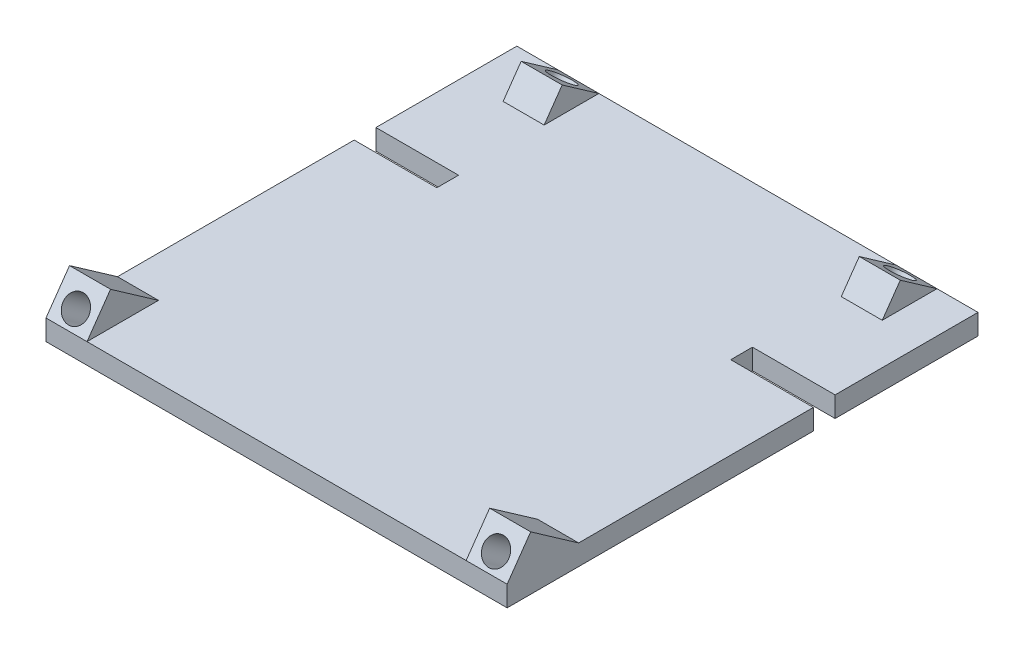
from build123d import *

# Parameters (mm, degrees)
BOSS_EXTRUDE1_DEPTH = 2.5
BOSS_EXTRUDE2_DEPTH = 10
SKETCH3_R           = 3.1
CUT_EXTRUDE1_DEPTH  = 97.926231277
BOSS_EXTRUDE3_DEPTH = 10
SKETCH5_R           = 3.1
CUT_EXTRUDE2_DEPTH  = 73.924932584
SKETCH6_W           = 5.175957564
SKETCH6_H           = 5
CUT_EXTRUDE3_DEPTH  = 113.454585159


with BuildPart() as part:
    # Sketch1 → Boss-Extrude1 (new body, symmetric)
    with BuildSketch(Plane(origin=(-32.81203924, 33.9517387, -54.90733973), x_dir=(-1, 0, 0), z_dir=(0, -1, 0))):
        Polygon((57.454585159, 35), (-55, 35), (-55, 0.15), (-34.85, 0.15), (-34.85, -5.15), (-55, -5.15), (-55, -85), (57.454585159, -85), (57.454585159, -4.673151813), (37.304585159, -4.673151813), (37.304585159, 0.626848187), (57.454585159, 0.626848187), align=None)
    extrude(amount=BOSS_EXTRUDE1_DEPTH, both=True)

    # Sketch2 → Boss-Extrude2 (add)
    with BuildSketch(Plane.ZY.offset(90.266624399)):
        Polygon((7.48223475, 36.4517387), (19.180938343, 44.643259143), (24.916702706, 36.4517387), align=None)
    boss_extrude2 = extrude(amount=-BOSS_EXTRUDE2_DEPTH)

    # Sketch3 → Cut-Extrude1 (cut, through all)
    with BuildSketch(Plane(origin=(0, 23.699275736, 33.846073404), x_dir=(1, 0, 0), z_dir=(0, 0.573576436, 0.819152044))):
        with Locations((-85.266624399, 19.56788273)):
            Circle(SKETCH3_R)
    cut_extrude1 = extrude(amount=-CUT_EXTRUDE1_DEPTH, mode=Mode.SUBTRACT)

    # Sketch4 → Boss-Extrude3 (add)
    with BuildSketch(Plane(origin=(-70.266624399, 0, 0), x_dir=(0, 0, -1), z_dir=(1, 0, 0))):
        Polygon((76.559676692, 36.4517387), (80.950923398, 42.723088931), (89.90733973, 36.4517387), align=None)
    boss_extrude3 = extrude(amount=-BOSS_EXTRUDE3_DEPTH)

    # Sketch5 → Cut-Extrude2 (cut, through all)
    with BuildSketch(Plane(origin=(0, 66.702115647, -46.70532419), x_dir=(1, 0, 0), z_dir=(0, 0.819152044, -0.573576436))):
        with Locations((-75.266624399, 47.80615729)):
            Circle(SKETCH5_R)
    cut_extrude2 = extrude(amount=-CUT_EXTRUDE2_DEPTH, mode=Mode.SUBTRACT)

    # Mirror1: Boss-Extrude2, Cut-Extrude1, Boss-Extrude3, Cut-Extrude2 across plane
    add(boss_extrude2.mirror(Plane.ZY.offset(34.03933182)))
    add(cut_extrude1.mirror(Plane.ZY.offset(34.03933182)), mode=Mode.SUBTRACT)
    add(boss_extrude3.mirror(Plane.ZY.offset(34.03933182)))
    add(cut_extrude2.mirror(Plane.ZY.offset(34.03933182)), mode=Mode.SUBTRACT)

    # Sketch6 → Cut-Extrude3 (cut, through all)
    with BuildSketch(Plane.ZY.offset(90.266624399)):
        with Locations((27.504681488, 33.9517387)):
            Rectangle(SKETCH6_W, SKETCH6_H)
    extrude(amount=-CUT_EXTRUDE3_DEPTH, mode=Mode.SUBTRACT)


solid = part.part
